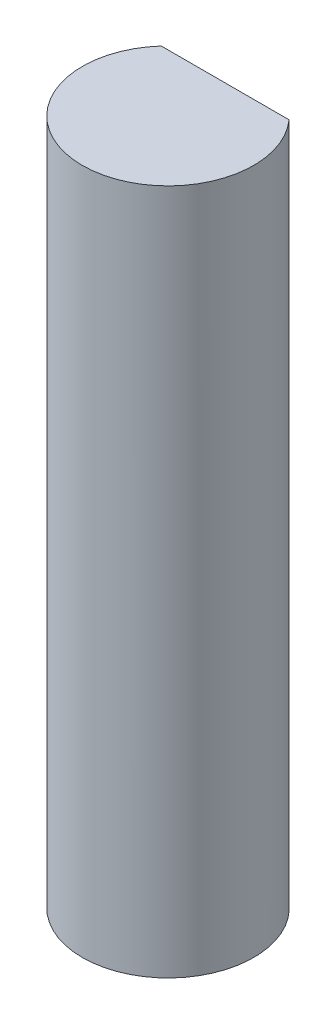
from build123d import *

# Parameters (mm, degrees)
SKETCH_1_R          = 1.5
EXTRUDE_1_DEPTH     = 10
CUT_EXTRUDE_START   = -10
CUT_EXTRUDE_1_DEPTH = 10
BOSS_EXTRUDE1_START = 2
SKETCH1_R           = 1.5
BOSS_EXTRUDE1_DEPTH = 2


with BuildPart() as part:
    # 草图1 → 凸台-拉伸1 (new body)
    with BuildSketch(Plane(origin=(0, 0, 0), x_dir=(1, 0, 0), z_dir=(0, 1, 0))):
        Circle(SKETCH_1_R)
    extrude(amount=EXTRUDE_1_DEPTH)

    # 草图2 → 切除-拉伸1 (cut)
    with BuildSketch(Plane(origin=(0, 10, 0), x_dir=(1, 0, 0), z_dir=(0, 1, 0)).offset(CUT_EXTRUDE_START)):
        with BuildLine():
            Line((-1.118033989, 1), (1.118033989, 1))
            ThreePointArc((1.118033989, 1), (0, 1.5), (-1.118033989, 1))
        make_face()
    extrude(amount=CUT_EXTRUDE_1_DEPTH, mode=Mode.SUBTRACT)

    # Sketch1 → Boss-Extrude1 (add)
    with BuildSketch(Plane.XZ.offset(BOSS_EXTRUDE1_START)):
        Circle(SKETCH1_R)
    extrude(amount=-BOSS_EXTRUDE1_DEPTH)


solid = part.part
